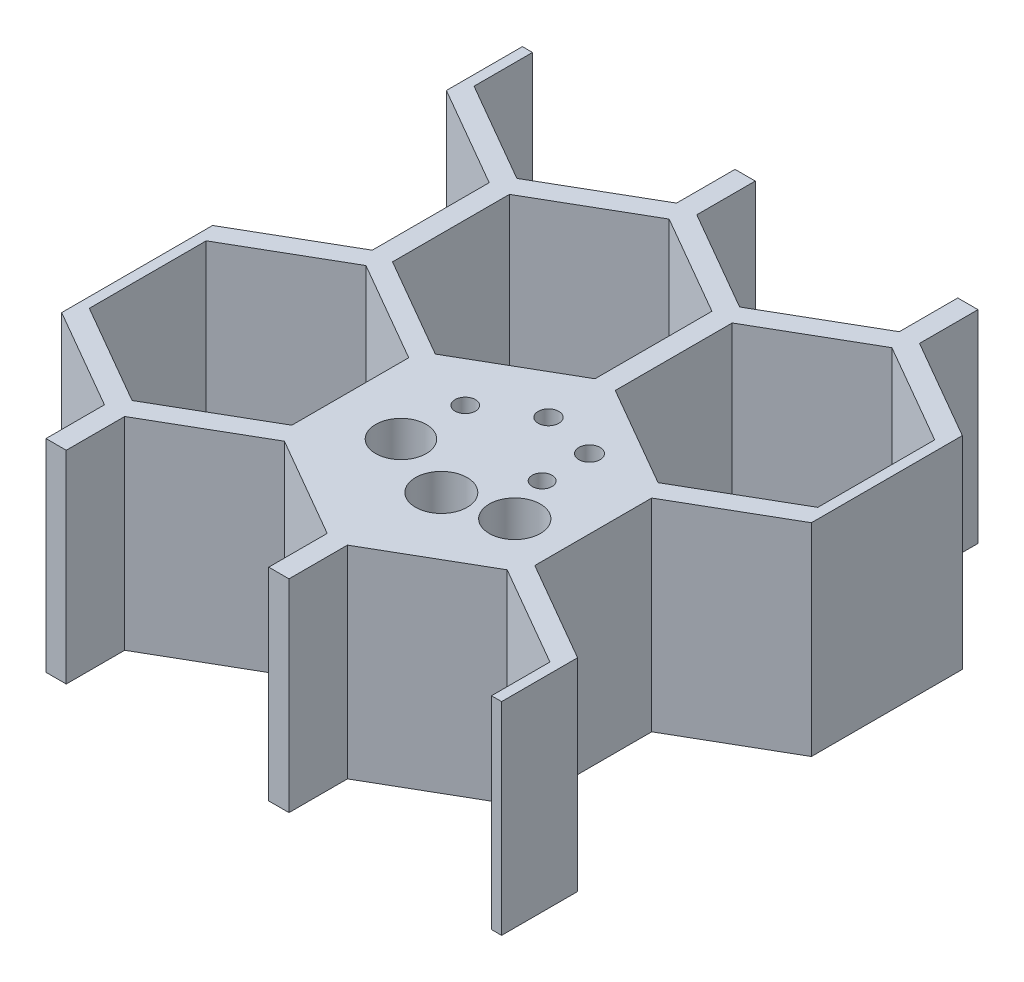
from build123d import *

# Parameters (mm, degrees)
BOSS_EXTRUDE2_DEPTH = 20
SKETCH2_R           = 1.025
SKETCH2_R_2         = 1.05
SKETCH2_R_3         = 0.975
SKETCH2_R_4         = 1
SKETCH2_R_5         = 2.5
SKETCH2_R_6         = 2.55
SKETCH2_R_7         = 2.525
BOSS_EXTRUDE3_DEPTH = 20


with BuildPart() as part:
    # Sketch1 → Boss-Extrude2 (new body)
    with BuildSketch(Plane(origin=(0, 0, 0), x_dir=(1, 0, 0), z_dir=(0, 1, 0))):
        Polygon((21, -13.279056191), (21, -19.052558883), (23, -19.052558883), (23, -13.279056191), (33, -7.505553499), (43, -13.279056191), (43, -19.052558883), (45, -19.052558883), (45, -13.279056191), (55, -7.505553499), (65, -13.279056191), (65, -19.052558883), (66, -19.052558883), (66, -11.547005384), (56, -5.773502692), (56, 5.773502692), (66, 11.547005384), (66, 26.452994616), (56, 32.226497308), (56, 38), (54, 38), (54, 32.226497308), (44, 26.452994616), (34, 32.226497308), (34, 38), (32, 38), (32, 32.226497308), (22, 26.452994616), (12, 32.226497308), (12, 38), (11, 38), (11, 30.494446501), (21, 24.720943809), (21, 13.173938425), (11, 7.400435733), (11, -7.505553499), align=None)
        Polygon((12, 5.773502692), (22, 11.547005384), (32, 5.773502692), (32, -5.773502692), (22, -11.547005384), (12, -5.773502692), align=None, mode=Mode.SUBTRACT)
        Polygon((34, 5.773502692), (44, 11.547005384), (54, 5.773502692), (54, -5.773502692), (44, -11.547005384), (34, -5.773502692), align=None, mode=Mode.SUBTRACT)
        Polygon((43, 13.173938425), (33, 7.400435733), (23, 13.173938425), (23, 24.720943809), (33, 30.494446501), (43, 24.720943809), align=None, mode=Mode.SUBTRACT)
        Polygon((65, 13.173938425), (55, 7.400435733), (45, 13.173938425), (45, 24.720943809), (55, 30.494446501), (65, 24.720943809), align=None, mode=Mode.SUBTRACT)
    extrude(amount=BOSS_EXTRUDE2_DEPTH)

    # Sketch2 → Boss-Extrude3 (add, through all)
    with BuildSketch(Plane(origin=(0, 20, 0), x_dir=(1, 0, 0), z_dir=(0, 1, 0))):
        Polygon((44, 11.547005384), (34, 5.773502692), (34, -5.773502692), (44, -11.547005384), (54, -5.773502692), (54, 5.773502692), align=None)
        with Locations((44, 7.57813322)):
            Circle(SKETCH2_R, mode=Mode.SUBTRACT)
        with Locations((49.12400919, 6.50535)):
            Circle(SKETCH2_R_2, mode=Mode.SUBTRACT)
        with Locations((49.12400919, 1.82801516)):
            Circle(SKETCH2_R_3, mode=Mode.SUBTRACT)
        with Locations((38.868201604, 4.488517546)):
            Circle(SKETCH2_R_4, mode=Mode.SUBTRACT)
        with Locations((38.567822302, -1.561979816)):
            Circle(SKETCH2_R_5, mode=Mode.SUBTRACT)
        with Locations((45.13325561, -4.136659545)):
            Circle(SKETCH2_R_6, mode=Mode.SUBTRACT)
        with Locations((51.012107657, -2.763497023)):
            Circle(SKETCH2_R_7, mode=Mode.SUBTRACT)
    extrude(amount=-BOSS_EXTRUDE3_DEPTH)


solid = part.part
